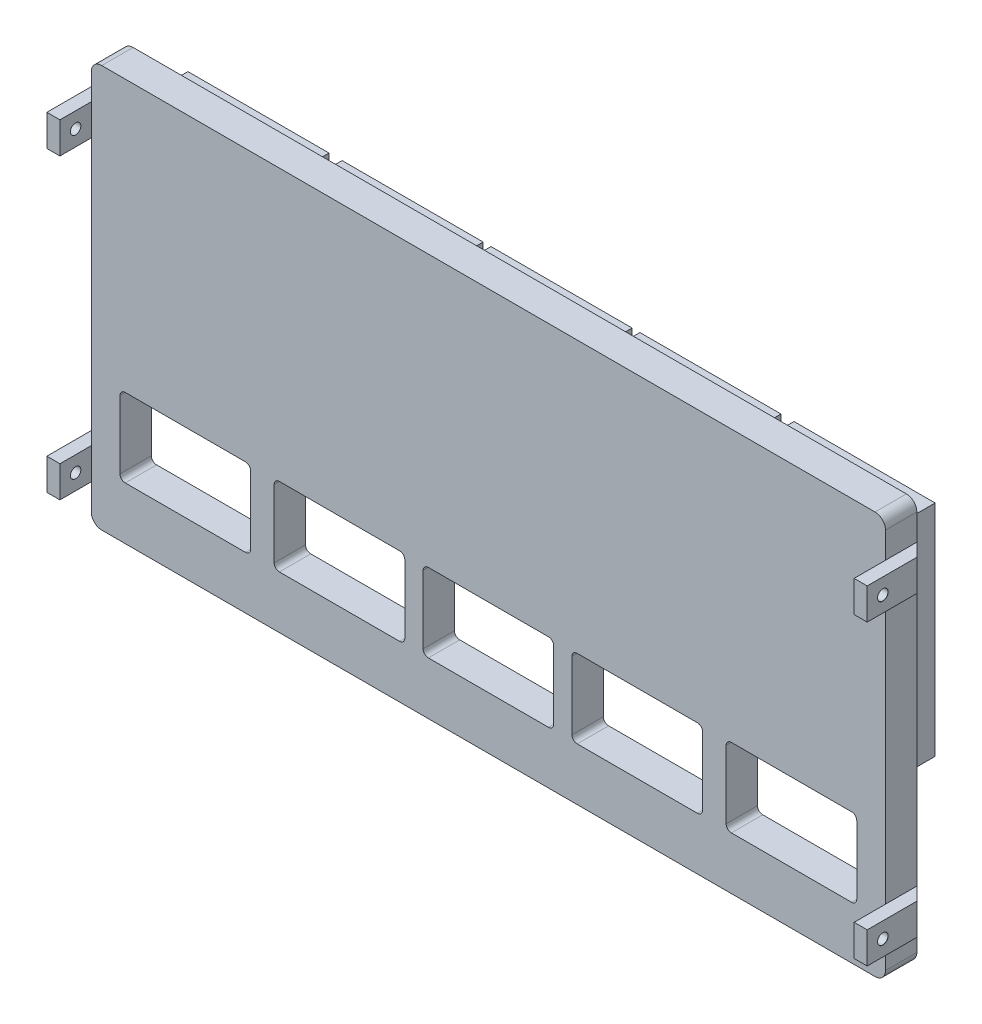
from build123d import *

# Parameters (mm, degrees)
IZIM1_W                     = 140
IZIM1_H                     = 65
Y_KSEKLIK_EKSTR_ZYON1_DEPTH = 25
BO_ALTMA3_T                 = 6
IZIM2_R                     = 2.25
KES_EKSTR_ZYON1_DEPTH       = 25
IZIM3_W                     = 13.33242511
IZIM3_H                     = 17.74072696
KES_EKSTR_ZYON2_DEPTH       = 25
RADYUS1_R                   = 2
IZIM2_2_R                   = 2.25
Y_KSEKLIK_EKSTR_ZYON2_DEPTH = 56
IZIM4_W                     = 373.647540747
IZIM4_H                     = 192.392001967
KES_EKSTR_ZYON3_DEPTH       = 1
IZIM5_R                     = 2.25
KES_EKSTR_ZYON4_DEPTH       = 25
IZIM6_W                     = 200.41848593
IZIM6_H                     = 96.929071346
KES_EKSTR_ZYON5_DEPTH       = 64
Y_KSEKLIK_EKSTR_ZYON3_DEPTH = 8
IZIM8_W                     = 25
IZIM8_H                     = 15
KES_EKSTR_ZYON6_DEPTH       = 8
RADYUS2_R                   = 1
IZIM9_W                     = 25
IZIM9_H                     = 1
Y_KSEKLIK_EKSTR_ZYON4_DEPTH = 4
IZIM10_W                    = 166.632718254
IZIM10_H                    = 87.088556488
KES_EKSTR_ZYON7_DEPTH       = 38
IZIM11_W                    = 12
IZIM11_H                    = 6
IZIM11_R                    = 1
Y_KSEKLIK_EKSTR_ZYON8_DEPTH = 2.5
IZIM20_W                    = 12
IZIM20_H                    = 6
IZIM20_R                    = 1
Y_KSEKLIK_EKSTR_ZYON9_DEPTH = 2.5
M2_DI_LI_DELIK1_D           = 1.6
M2_DI_LI_DELIK1_CSINK_D     = 2.05
M2_DI_LI_DELIK1_CSINK_ANGLE = 82
M2_DI_LI_DELIK2_D           = 1.6
M2_DI_LI_DELIK2_CSINK_D     = 2.05
M2_DI_LI_DELIK2_CSINK_ANGLE = 82
PAH1_SIZE                   = 2.5


with BuildPart() as part:
    # izim1 → Y_kseklik-Ekstr_zyon1 (new body)
    with BuildSketch(Plane.XY):
        Rectangle(IZIM1_W, IZIM1_H)
    extrude(amount=Y_KSEKLIK_EKSTR_ZYON1_DEPTH)

    # Bo_altma3
    bo_altma3_openings = [part.faces().sort_by_distance(p)[0] for p in [
        (0, 0, 0),
    ]]
    offset(amount=BO_ALTMA3_T, openings=bo_altma3_openings, kind=Kind.INTERSECTION)

    # izim2 → Kes-Ekstr_zyon1 (cut)
    with BuildSketch(Plane(origin=(0, 0, 0), x_dir=(-1, 0, 0), z_dir=(0, 0, -1))):
        with Locations((-73, -35.5)):
            Circle(IZIM2_R)
        with Locations(Location((73, -35.5, 0), (0, 0, 180))):
            Circle(IZIM2_R)
        with Locations(Location((-73, 35.5, 0), (0, 0, 180))):
            Circle(IZIM2_R)
        with Locations((73, 35.5)):
            Circle(IZIM2_R)
    extrude(amount=-KES_EKSTR_ZYON1_DEPTH, mode=Mode.SUBTRACT)

    # izim3 → Kes-Ekstr_zyon2 (cut)
    with BuildSketch(Plane.ZY.offset(-70)):
        with Locations((15.822558672, 0)):
            Rectangle(IZIM3_W, IZIM3_H)
    extrude(amount=-KES_EKSTR_ZYON2_DEPTH, mode=Mode.SUBTRACT)

    # Radyus1
    radyus1_edges = [part.edges().sort_by_distance(p)[0] for p in [
        (76, -38.5, 15.5),
        (-76, -38.5, 15.5),
        (-76, 38.5, 15.5),
        (76, 38.5, 15.5),
    ]]
    fillet(radyus1_edges, radius=RADYUS1_R)

    # izim2_2 → Y_kseklik-Ekstr_zyon2 (add)
    with BuildSketch(Plane(origin=(0, 0, 0), x_dir=(-1, 0, 0), z_dir=(0, 0, -1))):
        with Locations((-73, -35.5)):
            Circle(IZIM2_2_R)
        with Locations((73, -35.5)):
            Circle(IZIM2_2_R)
        with Locations((-73, 35.5)):
            Circle(IZIM2_2_R)
        with Locations((73, 35.5)):
            Circle(IZIM2_2_R)
    extrude(amount=-Y_KSEKLIK_EKSTR_ZYON2_DEPTH)

    # izim4 → Kes-Ekstr_zyon3 (cut)
    with BuildSketch(Plane.XY.offset(56)):
        with Locations((-92.221826013, 44.195860188)):
            Rectangle(IZIM4_W, IZIM4_H)
    extrude(amount=-KES_EKSTR_ZYON3_DEPTH, mode=Mode.SUBTRACT)

    # izim5 → Kes-Ekstr_zyon4 (cut)
    with BuildSketch(Plane(origin=(0, 0, 0), x_dir=(-1, 0, 0), z_dir=(0, 0, -1))):
        with Locations((-73, -35.527793561)):
            Circle(IZIM5_R)
        with Locations(Location((-73, 35.527793561, 0), (0, 0, 180))):
            Circle(IZIM5_R)
        with Locations((73, 35.527793561)):
            Circle(IZIM5_R)
        with Locations(Location((73, -35.527793561, 0), (0, 0, 180))):
            Circle(IZIM5_R)
    extrude(amount=-KES_EKSTR_ZYON4_DEPTH, mode=Mode.SUBTRACT)

    # izim6 → Kes-Ekstr_zyon5 (cut)
    with BuildSketch(Plane(origin=(0, 0, 25), x_dir=(-1, 0, 0), z_dir=(0, 0, -1))):
        Rectangle(IZIM6_W, IZIM6_H)
    extrude(amount=KES_EKSTR_ZYON5_DEPTH, mode=Mode.SUBTRACT)

    # izim7 → Y_kseklik-Ekstr_zyon3 (add)
    with BuildSketch(Plane(origin=(0, 0, 25), x_dir=(-1, 0, 0), z_dir=(0, 0, -1))):
        Polygon((-63, -9.252914509), (-63, -10.252914509), (-71.5, -10.252914509), (-71.5, 31.747085491), (-44.5, 31.747085491), (-44.5, -10.252914509), (-53, -10.252914509), (-53, -9.252914509), (-45.5, -9.252914509), (-45.5, 30.747085491), (-70.5, 30.747085491), (-70.5, -9.252914509), align=None)
        Polygon((53, -9.252914509), (45.5, -9.252914509), (45.5, 30.747085491), (70.5, 30.747085491), (70.5, -9.252914509), (63, -9.252914509), (63, -10.252914509), (71.5, -10.252914509), (71.5, 31.747085491), (44.5, 31.747085491), (44.5, -10.252914509), (53, -10.252914509), align=None)
        Polygon((-33.5, -9.252914509), (-41, -9.252914509), (-41, 30.747085491), (-16, 30.747085491), (-16, -9.252914509), (-23.5, -9.252914509), (-23.5, -10.252914509), (-15, -10.252914509), (-15, 31.747085491), (-42, 31.747085491), (-42, -10.252914509), (-33.5, -10.252914509), align=None)
        Polygon((23.5, -9.252914509), (23.5, -10.252914509), (15, -10.252914509), (15, 31.747085491), (42, 31.747085491), (42, -10.252914509), (33.5, -10.252914509), (33.5, -9.252914509), (41, -9.252914509), (41, 30.747085491), (16, 30.747085491), (16, -9.252914509), align=None)
        Polygon((13.5, 31.747085491), (13.5, -10.252914509), (5, -10.252914509), (5, -9.252914509), (12.5, -9.252914509), (12.5, 30.747085491), (-12.5, 30.747085491), (-12.5, -9.252914509), (-5, -9.252914509), (-5, -10.252914509), (-13.5, -10.252914509), (-13.5, 31.747085491), align=None)
    extrude(amount=Y_KSEKLIK_EKSTR_ZYON3_DEPTH)

    # izim8 → Kes-Ekstr_zyon6 (cut)
    with BuildSketch(Plane(origin=(0, 0, 25), x_dir=(-1, 0, 0), z_dir=(0, 0, -1))):
        with Locations((-58, -20.932185714)):
            Rectangle(IZIM8_W, IZIM8_H)
        with Locations((-28.5, -20.932185714)):
            Rectangle(IZIM8_W, IZIM8_H)
        with Locations((28.5, -20.932185714)):
            Rectangle(IZIM8_W, IZIM8_H)
        with Locations((58, -20.932185714)):
            Rectangle(IZIM8_W, IZIM8_H)
        with Locations((0, -20.932185714)):
            Rectangle(IZIM8_W, IZIM8_H)
    extrude(amount=-KES_EKSTR_ZYON6_DEPTH, mode=Mode.SUBTRACT)

    # Radyus2
    radyus2_edges = [part.edges().sort_by_distance(p)[0] for p in [
        (70.5, -28.432185714, 28),
        (70.5, -13.432185714, 28),
        (45.5, -13.432185714, 28),
        (45.5, -28.432185714, 28),
        (12.5, -28.432185714, 28),
        (12.5, -13.432185714, 28),
        (-12.5, -13.432185714, 28),
        (-12.5, -28.432185714, 28),
        (-70.5, -28.432185714, 28),
        (-45.5, -28.432185714, 28),
        (-45.5, -13.432185714, 28),
        (-70.5, -13.432185714, 28),
        (-16, -28.432185714, 28),
        (-16, -13.432185714, 28),
        (-41, -13.432185714, 28),
        (-41, -28.432185714, 28),
        (16, -28.432185714, 28),
        (41, -28.432185714, 28),
        (41, -13.432185714, 28),
        (16, -13.432185714, 28),
    ]]
    fillet(radyus2_edges, radius=RADYUS2_R)

    # izim9 → Y_kseklik-Ekstr_zyon4 (add)
    with BuildSketch(Plane(origin=(0, 0, 17), x_dir=(-1, 0, 0), z_dir=(0, 0, -1))):
        with Locations((-58, -9.752914509)):
            Rectangle(IZIM9_W, IZIM9_H)
        with Locations((-28.5, -9.752914509)):
            Rectangle(IZIM9_W, IZIM9_H)
        with Locations((0, -9.752914509)):
            Rectangle(IZIM9_W, IZIM9_H)
        with Locations((28.5, -9.752914509)):
            Rectangle(IZIM9_W, IZIM9_H)
        with Locations((58, -9.752914509)):
            Rectangle(IZIM9_W, IZIM9_H)
    extrude(amount=-Y_KSEKLIK_EKSTR_ZYON4_DEPTH)

    # izim10 → Kes-Ekstr_zyon7 (cut)
    with BuildSketch(Plane.XY.offset(31)):
        Rectangle(IZIM10_W, IZIM10_H)
    extrude(amount=KES_EKSTR_ZYON7_DEPTH, mode=Mode.SUBTRACT)

    # izim11 → Y_kseklik-Ekstr_zyon8 (add)
    with BuildSketch(Plane.ZY.offset(76)):
        with Locations((31, -28.5)):
            Rectangle(IZIM11_W, IZIM11_H)
        with Locations((34, -28.5)):
            Circle(IZIM11_R, mode=Mode.SUBTRACT)
        with Locations((31, 28.5)):
            Rectangle(IZIM11_W, IZIM11_H)
        with Locations(Location((34, 28.5, 0), (0, 0, 180))):
            Circle(IZIM11_R, mode=Mode.SUBTRACT)
    extrude(amount=Y_KSEKLIK_EKSTR_ZYON8_DEPTH)

    # izim20 → Y_kseklik-Ekstr_zyon9 (add)
    with BuildSketch(Plane(origin=(76, 0, 0), x_dir=(0, 0, -1), z_dir=(1, 0, 0))):
        with Locations((-31, 28.5)):
            Rectangle(IZIM20_W, IZIM20_H)
        with Locations((-34, 28.5)):
            Circle(IZIM20_R, mode=Mode.SUBTRACT)
        with Locations((-31, -28.5)):
            Rectangle(IZIM20_W, IZIM20_H)
        with Locations(Location((-34, -28.5, 0), (0, 0, 180))):
            Circle(IZIM20_R, mode=Mode.SUBTRACT)
    extrude(amount=Y_KSEKLIK_EKSTR_ZYON9_DEPTH)

    # M2 Di_li Delik1 (through all)
    with Locations(Plane(origin=(78.5, -28.5, 34), x_dir=(0, 0, 1), z_dir=(1, 0, 0))):
        with Locations((0, 0), (0, -57)):
            CounterSinkHole(M2_DI_LI_DELIK1_D / 2, M2_DI_LI_DELIK1_CSINK_D / 2, counter_sink_angle=M2_DI_LI_DELIK1_CSINK_ANGLE)

    # M2 Di_li Delik2 (through all)
    with Locations(Plane(origin=(-78.5, -28.5, 34), x_dir=(0, 0, -1), z_dir=(-1, 0, 0))):
        with Locations((0, 0), (0, -57)):
            CounterSinkHole(M2_DI_LI_DELIK2_D / 2, M2_DI_LI_DELIK2_CSINK_D / 2, counter_sink_angle=M2_DI_LI_DELIK2_CSINK_ANGLE)

    # Pah1
    pah1_edges = [part.edges().sort_by_distance(p)[0] for p in [
        (78.5, 28.5, 25),
        (78.5, -28.5, 25),
        (-78.5, 28.5, 25),
        (-78.5, -28.5, 25),
    ]]
    chamfer(pah1_edges, length=PAH1_SIZE)


solid = part.part
